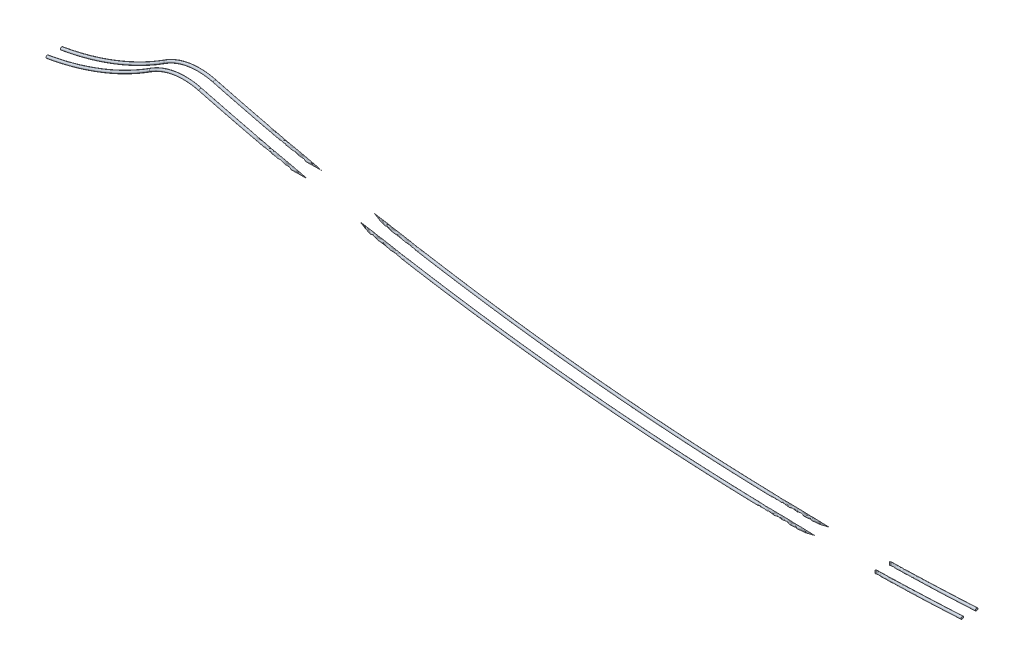
from build123d import *

# Parameters (mm, degrees)
SKETCH_2_R = 0.75


with BuildPart() as part:
    # 掃出1: sweep along a path in 草圖1
    with BuildLine(Plane.XY) as sweep_1_path:
        ThreePointArc((0, 0), (29.927252892, 8.322331102), (57.622362574, 22.389404723))
        ThreePointArc((57.622362574, 22.389404723), (70.860739212, 27.416036901), (85.003598536, 26.708098215))
        ThreePointArc((85.003598536, 26.708098215), (295.22001087, -11.16298749), (508.769754915, -15.817658898))
    # 草圖2 → 掃出1 (sweep)
    with BuildSketch(Plane(origin=(0, 0, 0), x_dir=(0, 0, -1), z_dir=(1, 0, 0))):
        with Locations((-4, 0)):
            Circle(SKETCH_2_R)
        with Locations((4, 0)):
            Circle(SKETCH_2_R)
    sweep(path=sweep_1_path.line)


solid = part.part
